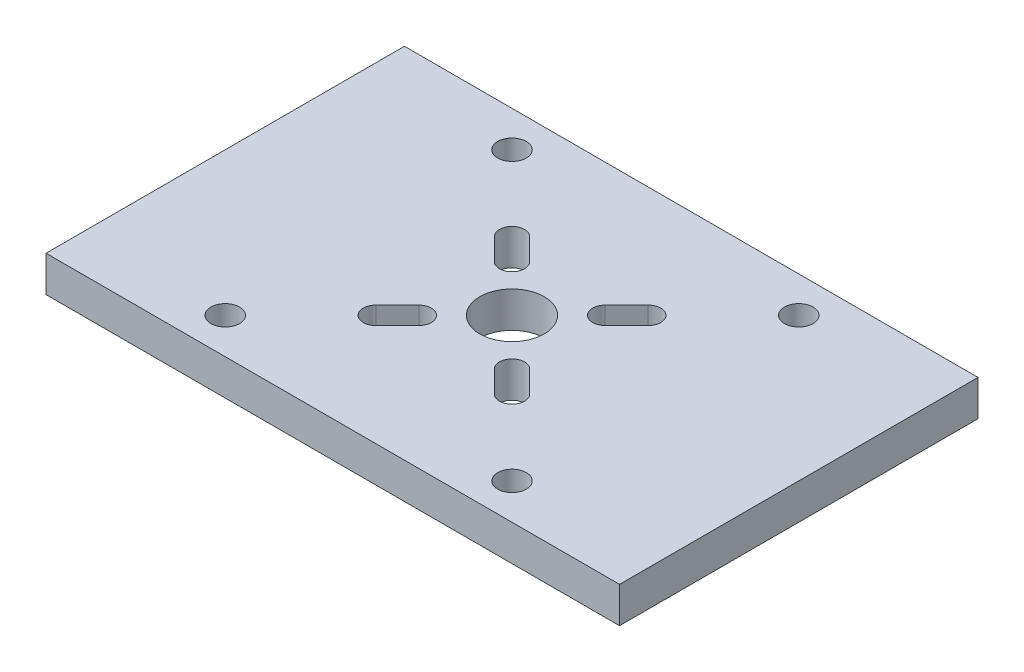
from build123d import *

# Parameters (mm, degrees)
SKETCH1_W          = 160
SKETCH1_H          = 100
BASE_DEPTH         = 10
SKETCH2_R          = 9
ACTUATOR_CUT_DEPTH = 40
CUT_EXTRUDE1_REACH = 12
CUT_EXTRUDE2_REACH = 12
SKETCH5_R          = 3
SKETCH6_R          = 4
CUT_EXTRUDE3_DEPTH = 11


with BuildPart() as part:
    # Sketch1 → base (new body)
    with BuildSketch(Plane(origin=(0, 0, 0), x_dir=(1, 0, 0), z_dir=(0, 1, 0))):
        Rectangle(SKETCH1_W, SKETCH1_H)
    extrude(amount=BASE_DEPTH)

    # Sketch2 → actuator cut (cut)
    with BuildSketch(Plane(origin=(0, 10, 0), x_dir=(1, 0, 0), z_dir=(0, 1, 0))):
        Circle(SKETCH2_R)
    extrude(amount=-ACTUATOR_CUT_DEPTH, mode=Mode.SUBTRACT)

    # Sketch3 → Cut-Extrude1 (cut, up to next)
    with BuildSketch(Plane(origin=(0, 10, 0), x_dir=(1, 0, 0), z_dir=(0, 1, 0)), mode=Mode.PRIVATE) as cut_extrude1_sk1:
        with BuildLine():
            Line((-21.474873734, -16.525126266), (-15.474873734, -10.525126266))
            ThreePointArc((-15.474873734, -10.525126266), (-10.525126266, -10.525126266), (-10.525126266, -15.474873734))
            Line((-10.525126266, -15.474873734), (-16.525126266, -21.474873734))
            ThreePointArc((-16.525126266, -21.474873734), (-21.474873734, -21.474873734), (-21.474873734, -16.525126266))
        make_face()
    cut_extrude1_tool1 = extrude(cut_extrude1_sk1.sketch, amount=-CUT_EXTRUDE1_REACH, mode=Mode.PRIVATE) & part.part
    add(cut_extrude1_tool1.solids().sort_by_distance((-16, 10, 16))[0], mode=Mode.SUBTRACT)
    # Sketch3 → Cut-Extrude1 (cut, up to next)
    with BuildSketch(Plane(origin=(0, 10, 0), x_dir=(1, 0, 0), z_dir=(0, 1, 0)), mode=Mode.PRIVATE) as cut_extrude1_sk2:
        with BuildLine():
            Line((21.474873734, -16.525126266), (15.474873734, -10.525126266))
            ThreePointArc((15.474873734, -10.525126266), (10.525126266, -10.525126266), (10.525126266, -15.474873734))
            Line((10.525126266, -15.474873734), (16.525126266, -21.474873734))
            ThreePointArc((16.525126266, -21.474873734), (21.474873734, -21.474873734), (21.474873734, -16.525126266))
        make_face()
    cut_extrude1_tool2 = extrude(cut_extrude1_sk2.sketch, amount=-CUT_EXTRUDE1_REACH, mode=Mode.PRIVATE) & part.part
    add(cut_extrude1_tool2.solids().sort_by_distance((16, 10, 16))[0], mode=Mode.SUBTRACT)
    # Sketch3 → Cut-Extrude1 (cut, up to next)
    with BuildSketch(Plane(origin=(0, 10, 0), x_dir=(1, 0, 0), z_dir=(0, 1, 0)), mode=Mode.PRIVATE) as cut_extrude1_sk3:
        with BuildLine():
            Line((21.474873734, 16.525126266), (15.474873734, 10.525126266))
            ThreePointArc((15.474873734, 10.525126266), (10.525126266, 10.525126266), (10.525126266, 15.474873734))
            Line((10.525126266, 15.474873734), (16.525126266, 21.474873734))
            ThreePointArc((16.525126266, 21.474873734), (21.474873734, 21.474873734), (21.474873734, 16.525126266))
        make_face()
    cut_extrude1_tool3 = extrude(cut_extrude1_sk3.sketch, amount=-CUT_EXTRUDE1_REACH, mode=Mode.PRIVATE) & part.part
    add(cut_extrude1_tool3.solids().sort_by_distance((16, 10, -16))[0], mode=Mode.SUBTRACT)
    # Sketch3 → Cut-Extrude1 (cut, up to next)
    with BuildSketch(Plane(origin=(0, 10, 0), x_dir=(1, 0, 0), z_dir=(0, 1, 0)), mode=Mode.PRIVATE) as cut_extrude1_sk4:
        with BuildLine():
            Line((-21.474873734, 16.525126266), (-15.474873734, 10.525126266))
            ThreePointArc((-15.474873734, 10.525126266), (-10.525126266, 10.525126266), (-10.525126266, 15.474873734))
            Line((-10.525126266, 15.474873734), (-16.525126266, 21.474873734))
            ThreePointArc((-16.525126266, 21.474873734), (-21.474873734, 21.474873734), (-21.474873734, 16.525126266))
        make_face()
    cut_extrude1_tool4 = extrude(cut_extrude1_sk4.sketch, amount=-CUT_EXTRUDE1_REACH, mode=Mode.PRIVATE) & part.part
    add(cut_extrude1_tool4.solids().sort_by_distance((-16, 10, -16))[0], mode=Mode.SUBTRACT)

    # Sketch5 → Cut-Extrude2 (cut, up to next)
    with BuildSketch(Plane(origin=(0, 10, 0), x_dir=(1, 0, 0), z_dir=(0, 1, 0)), mode=Mode.PRIVATE) as cut_extrude2_sk1:
        with Locations((-40, -40)):
            Circle(SKETCH5_R)
    cut_extrude2_tool1 = extrude(cut_extrude2_sk1.sketch, amount=-CUT_EXTRUDE2_REACH, mode=Mode.PRIVATE) & part.part
    add(cut_extrude2_tool1.solids().sort_by_distance((-40, 10, 40))[0], mode=Mode.SUBTRACT)
    # Sketch5 → Cut-Extrude2 (cut, up to next)
    with BuildSketch(Plane(origin=(0, 10, 0), x_dir=(1, 0, 0), z_dir=(0, 1, 0)), mode=Mode.PRIVATE) as cut_extrude2_sk2:
        with Locations((-40, 40)):
            Circle(SKETCH5_R)
    cut_extrude2_tool2 = extrude(cut_extrude2_sk2.sketch, amount=-CUT_EXTRUDE2_REACH, mode=Mode.PRIVATE) & part.part
    add(cut_extrude2_tool2.solids().sort_by_distance((-40, 10, -40))[0], mode=Mode.SUBTRACT)
    # Sketch5 → Cut-Extrude2 (cut, up to next)
    with BuildSketch(Plane(origin=(0, 10, 0), x_dir=(1, 0, 0), z_dir=(0, 1, 0)), mode=Mode.PRIVATE) as cut_extrude2_sk3:
        with Locations((40, -40)):
            Circle(SKETCH5_R)
    cut_extrude2_tool3 = extrude(cut_extrude2_sk3.sketch, amount=-CUT_EXTRUDE2_REACH, mode=Mode.PRIVATE) & part.part
    add(cut_extrude2_tool3.solids().sort_by_distance((40, 10, 40))[0], mode=Mode.SUBTRACT)
    # Sketch5 → Cut-Extrude2 (cut, up to next)
    with BuildSketch(Plane(origin=(0, 10, 0), x_dir=(1, 0, 0), z_dir=(0, 1, 0)), mode=Mode.PRIVATE) as cut_extrude2_sk4:
        with Locations((40, 40)):
            Circle(SKETCH5_R)
    cut_extrude2_tool4 = extrude(cut_extrude2_sk4.sketch, amount=-CUT_EXTRUDE2_REACH, mode=Mode.PRIVATE) & part.part
    add(cut_extrude2_tool4.solids().sort_by_distance((40, 10, -40))[0], mode=Mode.SUBTRACT)

    # Sketch6 → Cut-Extrude3 (cut, through all)
    with BuildSketch(Plane.XZ):
        with Locations((-40, 40)):
            Circle(SKETCH6_R)
        with Locations((40, 40)):
            Circle(SKETCH6_R)
        with Locations((40, -40)):
            Circle(SKETCH6_R)
        with Locations((-40, -40)):
            Circle(SKETCH6_R)
    extrude(amount=-CUT_EXTRUDE3_DEPTH, mode=Mode.SUBTRACT)


solid = part.part
